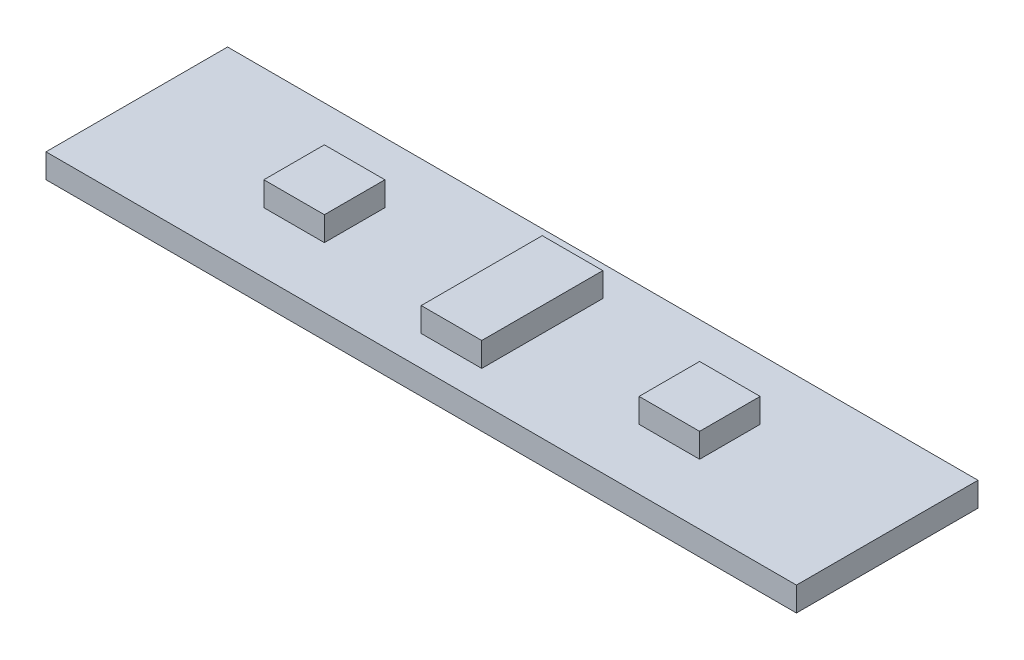
from build123d import *

# Parameters (mm, degrees)
SKETCH1_W           = 62
SKETCH1_H           = 15
BOSS_EXTRUDE1_DEPTH = 2
SKETCH2_W           = 5
SKETCH2_H           = 5
BOSS_EXTRUDE2_DEPTH = 2


with BuildPart() as part:
    # Sketch1 → Boss-Extrude1 (new body)
    with BuildSketch(Plane(origin=(0, 0, 0), x_dir=(1, 0, 0), z_dir=(0, 1, 0))):
        with Locations((31, 7.5)):
            Rectangle(SKETCH1_W, SKETCH1_H)
    extrude(amount=BOSS_EXTRUDE1_DEPTH)

    # Sketch2 → Boss-Extrude2 (add)
    with BuildSketch(Plane(origin=(0, 2, 0), x_dir=(1, 0, 0), z_dir=(0, 1, 0))):
        with Locations((15.5, 7.5)):
            Rectangle(SKETCH2_W, SKETCH2_H)
        with Locations((46.5, 7.5)):
            Rectangle(SKETCH2_W, SKETCH2_H)
        Polygon((31, 2.5), (28.5, 2.5), (28.5, 12.5), (33.5, 12.5), (33.5, 2.5), align=None)
    extrude(amount=BOSS_EXTRUDE2_DEPTH)


solid = part.part
